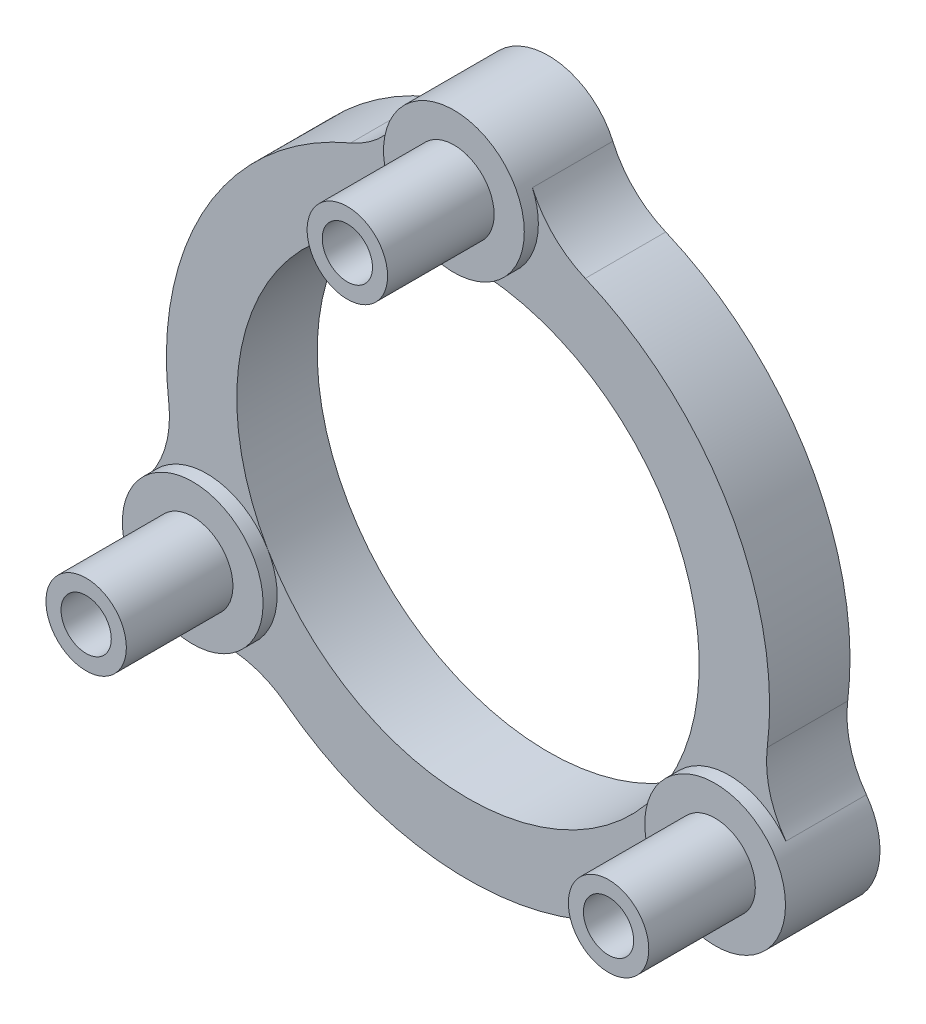
from build123d import *

# Parameters (mm, degrees)
SKETCH1_R                   = 18.5
SKETCH1_R_2                 = 11.5
BOSS_EXTRUDE1_DEPTH         = 4
SKETCH2_R                   = 2
BOSS_EXTRUDE2_DEPTH         = 6
TAP_DRILL_FOR_M3X0_5_TAP1_D = 2.5
CUT_EXTRUDE1_DEPTH          = 10
FILLET1_R                   = 5
SKETCH6_R                   = 3.5
SKETCH6_R_2                 = 2
BOSS_EXTRUDE3_DEPTH         = 0.7


with BuildPart() as part:
    # Sketch1 → Boss-Extrude1 (new body)
    with BuildSketch(Plane.XY):
        Circle(SKETCH1_R)
        Circle(SKETCH1_R_2, mode=Mode.SUBTRACT)
    extrude(amount=BOSS_EXTRUDE1_DEPTH)

    # Sketch2 → Boss-Extrude2 (add)
    with BuildSketch(Plane.XY.offset(4)):
        with Locations((0, 15)):
            Circle(SKETCH2_R)
        with Locations((12.990381057, -7.5)):
            Circle(SKETCH2_R)
        with Locations((-12.990381057, -7.5)):
            Circle(SKETCH2_R)
    extrude(amount=BOSS_EXTRUDE2_DEPTH)

    # Tap Drill for M3x0.5 Tap1 (through all)
    with Locations(Plane(origin=(0, 15, 10), x_dir=(1, 0, 0), z_dir=(0, 0, 1))):
        with Locations((0, 0), (12.990381057, -22.5), (-12.990381057, -22.5)):
            Hole(TAP_DRILL_FOR_M3X0_5_TAP1_D / 2)

    # Sketch5 → Cut-Extrude1 (cut)
    with BuildSketch(Plane.XY.offset(4)):
        with BuildLine():
            ThreePointArc((0, 18.5), (2.615259707, 17.326030238), (3.476098947, 14.591666667))
            ThreePointArc((3.476098947, 14.591666667), (12.990381057, 7.5), (14.37480349, -4.285443339))
            ThreePointArc((14.37480349, -4.285443339), (16.312412175, -6.398133741), (16.021470006, -9.249999937))
            ThreePointArc((16.021470006, -9.249999937), (16.021469952, 9.250000031), (0, 18.5))
        make_face()
        with BuildLine():
            ThreePointArc((-3.476098947, 14.591666667), (-2.615259707, 17.326030238), (0, 18.5))
            ThreePointArc((0, 18.5), (-16.021469952, 9.250000031), (-16.021470006, -9.249999937))
            ThreePointArc((-16.021470006, -9.249999937), (-16.312412175, -6.398133741), (-14.37480349, -4.285443339))
            ThreePointArc((-14.37480349, -4.285443339), (-12.990381057, 7.5), (-3.476098947, 14.591666667))
        make_face()
        with BuildLine():
            ThreePointArc((-10.898704543, -10.306223327), (-13.697152515, -10.927896455), (-16.021470006, -9.249999937))
            ThreePointArc((-16.021470006, -9.249999937), (0, -18.5), (16.021470006, -9.249999937))
            ThreePointArc((16.021470006, -9.249999937), (13.697152515, -10.927896455), (10.898704543, -10.306223327))
            ThreePointArc((10.898704543, -10.306223327), (0, -15), (-10.898704543, -10.306223327))
        make_face()
    extrude(amount=-CUT_EXTRUDE1_DEPTH, mode=Mode.SUBTRACT)

    # Fillet1
    fillet1_edges = [part.edges().sort_by_distance(p)[0] for p in [
        (-3.476098947, 14.591666667, 2),
        (-14.37480349, -4.285443339, 2),
        (14.37480349, -4.285443339, 2),
        (3.476098947, 14.591666667, 2),
        (-10.898704543, -10.306223327, 2),
        (10.898704543, -10.306223327, 2),
    ]]
    fillet(fillet1_edges, radius=FILLET1_R)

    # Sketch6 → Boss-Extrude3 (add)
    with BuildSketch(Plane.XY.offset(4)):
        with Locations((-12.990381057, -7.5)):
            Circle(SKETCH6_R)
        with Locations((-12.990381057, -7.5)):
            Circle(SKETCH6_R_2, mode=Mode.SUBTRACT)
        with Locations((0, 15)):
            Circle(SKETCH6_R)
        with Locations((0, 15)):
            Circle(SKETCH6_R_2, mode=Mode.SUBTRACT)
        with Locations((12.990381057, -7.5)):
            Circle(SKETCH6_R)
        with Locations((12.990381057, -7.5)):
            Circle(SKETCH6_R_2, mode=Mode.SUBTRACT)
    extrude(amount=BOSS_EXTRUDE3_DEPTH)


solid = part.part
